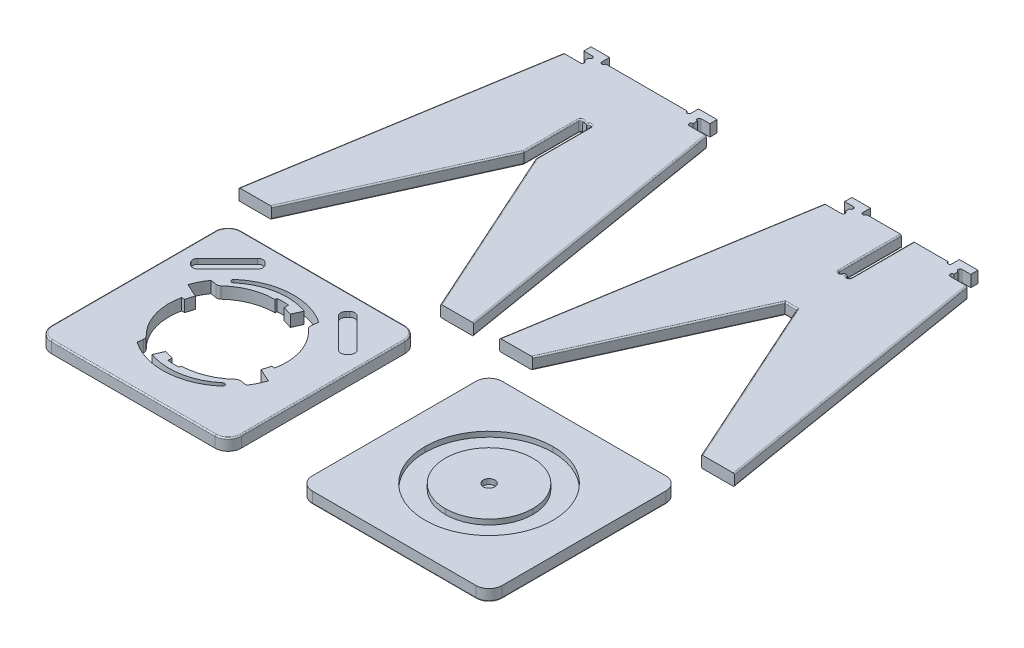
from build123d import *

# Parameters (mm, degrees)
BOSS_EXTRUDE1_DEPTH   = 18
BOSS_EXTRUDE1_2_DEPTH = 18
BOSS_EXTRUDE1_3_DEPTH = 18
BOSS_EXTRUDE1_4_DEPTH = 18
BOSS_EXTRUDE1_5_DEPTH = 18
CUT_EXTRUDE2_DEPTH    = 18
BOSS_EXTRUDE2_START   = -18
BOSS_EXTRUDE2_DEPTH   = 10
FILLET1_R             = 2
FILLET2_R             = 2
FILLET3_R             = 2
FILLET4_R             = 2


with BuildPart() as part:
    # Sketch6 → Boss-Extrude1 (new body)
    with BuildSketch(Plane(origin=(0, 0, 0), x_dir=(1, 0, 0), z_dir=(0, 1, 0))):
        with BuildLine():
            ThreePointArc((-197.70243538, 340.929264228), (-200.767441289, 343.994270137), (-203.832447198, 340.929264228))
            Line((-203.832447198, 340.929264228), (-203.832303055, 256.059392949))
            Line((-203.832303055, 256.059392949), (-325.993914385, -14.127247216))
            Line((-325.993914385, -14.127247216), (-377.067856833, -14.245443905))
            Line((-377.067856833, -14.245443905), (-305.754929566, 418.861386255))
            Line((-305.754929566, 418.861386255), (-279.221754846, 418.861386255))
            ThreePointArc((-279.221754846, 418.861386255), (-276.15673092, 421.926410182), (-279.221754846, 424.991434109))
            Line((-279.221754846, 424.991434109), (-279.221754846, 431.456216427))
            ThreePointArc((-279.221754846, 431.456216427), (-276.156640831, 434.521222336), (-279.22164674, 437.586336351))
            Line((-279.22164674, 437.586336351), (-292.6470609, 437.586156174))
            Line((-292.6470609, 437.586156174), (-292.647096936, 448.824571232))
            Line((-292.647096936, 448.824571232), (-263.847825025, 448.824391055))
            Line((-263.847825025, 448.824391055), (-263.847825025, 437.075351885))
            ThreePointArc((-263.847825025, 437.075351885), (-260.782765063, 434.010291923), (-257.7177051, 437.075351885))
            Line((-257.7177051, 437.075351885), (-131.557153841, 437.075351885))
            ThreePointArc((-131.557153841, 437.075351885), (-128.492039829, 434.010526149), (-125.427105988, 437.075532063))
            Line((-125.427105988, 437.075532063), (-125.427105988, 448.824571232))
            Line((-125.427105988, 448.824571232), (-96.627834076, 448.82475141))
            Line((-96.627834076, 448.82475141), (-96.627762005, 437.586336351))
            Line((-96.627762005, 437.586336351), (-110.053176166, 437.586336351))
            ThreePointArc((-110.053176166, 437.586336351), (-113.118272164, 434.521240353), (-110.053176166, 431.456144356))
            Line((-110.053176166, 431.456144356), (-110.053176166, 424.991362037))
            ThreePointArc((-110.053176166, 424.991362037), (-113.118164057, 421.926374146), (-110.053176166, 418.861386255))
            Line((-110.053176166, 418.861386255), (-83.520181624, 418.861386255))
            Line((-83.520181624, 418.861386255), (-12.206857966, -14.245515977))
            Line((-12.206857966, -14.245515977), (-63.280872485, -14.363784737))
            Line((-63.280872485, -14.363784737), (-185.442555886, 256.059609162))
            Line((-185.442555886, 256.059609162), (-185.442555886, 340.929264228))
            ThreePointArc((-185.442555886, 340.929264228), (-188.507489724, 343.994198066), (-191.572423562, 340.929264228))
            Line((-191.572423562, 340.929264228), (-197.70243538, 340.929264228))
        make_face()
    extrude(amount=BOSS_EXTRUDE1_DEPTH)

    # Fillet3
    fillet3_edges = [part.edges().sort_by_distance(p)[0] for p in [
        (-341.4113932, 18, -202.307971175),
        (-264.91310872, 18, -120.966072866),
        (-188.507489724, 18, -343.994198066),
        (-203.832375126, 18, -298.494328588),
        (-185.442555886, 18, -298.494436695),
        (-124.361714186, 18, -120.847912213),
        (-47.863519795, 18, -202.307935139),
        (-203.832375126, 0, -298.494328588),
        (-264.91310872, 0, -120.966072866),
        (-341.4113932, 0, -202.307971175),
        (-47.863519795, 0, -202.307935139),
        (-200.767441289, 18, -343.994270137),
        (-124.361714186, 0, -120.847912213),
        (-185.442555886, 0, -298.494436695),
        (-188.507489724, 0, -343.994198066),
        (-200.767441289, 0, -343.994270137),
    ]]
    fillet(fillet3_edges, radius=FILLET3_R)


with BuildPart() as body_2:
    # Sketch6 → Boss-Extrude1 2 (new body)
    with BuildSketch(Plane(origin=(0, 0, 0), x_dir=(1, 0, 0), z_dir=(0, 1, 0))):
        with BuildLine():
            Line((126.274869301, 431.456216427), (126.274869301, 424.991434109))
            ThreePointArc((126.274869301, 424.991434109), (129.339695037, 421.926410182), (126.274869301, 418.861386255))
            Line((126.274869301, 418.861386255), (99.741514403, 418.861386255))
            Line((99.741514403, 418.861386255), (28.428587137, -14.245515977))
            Line((28.428587137, -14.245515977), (79.502601656, -14.008762243))
            Line((79.502601656, -14.008762243), (201.663996772, 256.216904451))
            Line((201.663996772, 256.216904451), (220.164661444, 256.216904451))
            Line((220.164661444, 256.216904451), (342.155536215, -14.36367663))
            Line((342.155536215, -14.36367663), (393.289441861, -14.245515977))
            Line((393.289441861, -14.245515977), (321.976478559, 418.861386255))
            Line((321.976478559, 418.861386255), (295.443484017, 418.861386255))
            ThreePointArc((295.443484017, 418.861386255), (292.378496126, 421.926392164), (295.443520053, 424.991362037))
            Line((295.443520053, 424.991362037), (295.443520053, 431.456144356))
            ThreePointArc((295.443520053, 431.456144356), (292.378424055, 434.521240353), (295.443520053, 437.586336351))
            Line((295.443520053, 437.586336351), (308.868934213, 437.586336351))
            Line((308.868934213, 437.586336351), (308.868790071, 448.82475141))
            Line((308.868790071, 448.82475141), (280.06951816, 448.824571232))
            Line((280.06951816, 448.824571232), (280.069446089, 437.075532063))
            ThreePointArc((280.069446089, 437.075532063), (277.004530266, 434.01052615), (273.939434271, 437.075351885))
            Line((273.939434271, 437.075351885), (220.054356546, 437.075351885))
            Line((220.054356546, 437.075351885), (220.054104297, 340.730600098))
            ThreePointArc((220.054104297, 340.730600098), (217.043708877, 337.558462502), (213.924020408, 340.623178046))
            Line((213.924020408, 340.623178046), (207.79400859, 340.623178046))
            ThreePointArc((207.79400859, 340.623178046), (204.729002681, 337.558172137), (201.663996772, 340.623178046))
            Line((201.663996772, 340.623178046), (201.66417695, 437.075351885))
            Line((201.66417695, 437.075351885), (147.778738869, 437.075351885))
            ThreePointArc((147.778738869, 437.075351885), (144.713696925, 434.01030994), (141.64865498, 437.075351885))
            Line((141.64865498, 437.075351885), (141.64865498, 448.824391055))
            Line((141.64865498, 448.824391055), (112.849743425, 448.824571232))
            Line((112.849743425, 448.824571232), (112.849599283, 437.586156174))
            Line((112.849599283, 437.586156174), (126.275013443, 437.586336351))
            ThreePointArc((126.275013443, 437.586336351), (129.34011272, 434.521204315), (126.274869301, 431.456216427))
        make_face()
    extrude(amount=BOSS_EXTRUDE1_2_DEPTH)

    # Fillet4
    fillet4_edges = [body_2.edges().sort_by_distance(p)[0] for p in [
        (204.729002681, 0, -337.558172137),
        (204.729002681, 18, -337.558172137),
        (201.664086861, 0, -388.849264965),
        (220.054230422, 0, -388.902975991),
        (220.054230422, 18, -388.902975991),
        (201.664086861, 18, -388.849264965),
        (357.63296021, 0, -202.307935139),
        (357.63296021, 18, -202.307935139),
        (64.08505077, 0, -202.307935139),
        (64.08505077, 18, -202.307935139),
        (140.583299214, 0, -121.104071104),
        (140.583299214, 18, -121.104071104),
        (210.914329108, 0, -256.216904451),
        (210.914329108, 18, -256.216904451),
        (281.160098829, 0, -120.92661391),
        (281.160098829, 18, -120.92661391),
    ]]
    fillet(fillet4_edges, radius=FILLET4_R)


with BuildPart() as body_3:
    # Sketch6 → Boss-Extrude1 3 (new body)
    with BuildSketch(Plane(origin=(0, 0, 0), x_dir=(1, 0, 0), z_dir=(0, 1, 0))):
        with BuildLine():
            Line((88.692898723, -70.548220489), (342.99307507, -70.548220489))
            ThreePointArc((342.99307507, -70.548220489), (357.439018451, -76.531926159), (363.42272412, -90.977869539))
            Line((363.42272412, -90.977869539), (363.42272412, -345.277685531))
            ThreePointArc((363.42272412, -345.277685531), (357.439018451, -359.723628912), (342.99307507, -365.707334581))
            Line((342.99307507, -365.707334581), (88.692898723, -365.707334581))
            ThreePointArc((88.692898723, -365.707334581), (74.246955342, -359.723628912), (68.263249672, -345.277685531))
            Line((68.263249672, -345.277685531), (68.263249672, -90.977869539))
            ThreePointArc((68.263249672, -90.977869539), (74.246955342, -76.531926159), (88.692898723, -70.548220489))
        make_face()
        with BuildLine():
            add(Edge.make_bspline(
                [(215.84320311, -317.479662097), (270.71349348, -317.479662097), (315.195087671, -272.998428261), (315.195087671, -218.127777535)],
                knots=[3, 3, 3, 3, 4, 4, 4, 4], degree=3))
            add(Edge.make_bspline(
                [(315.195087671, -218.127777535), (315.195087671, -163.257126809), (270.71349348, -118.775892974), (215.84320311, -118.775892974)],
                knots=[0, 0, 0, 0, 1, 1, 1, 1], degree=3))
            add(Edge.make_bspline(
                [(215.84320311, -118.775892974), (160.972552384, -118.775892974), (116.490958193, -163.257126809), (116.490958193, -218.127777535)],
                knots=[1, 1, 1, 1, 2, 2, 2, 2], degree=3))
            add(Edge.make_bspline(
                [(116.490958193, -218.127777535), (116.490958193, -272.998428261), (160.972552384, -317.479662097), (215.84320311, -317.479662097)],
                knots=[2, 2, 2, 2, 3, 3, 3, 3], degree=3))
        make_face(mode=Mode.SUBTRACT)
    extrude(amount=BOSS_EXTRUDE1_3_DEPTH)



with BuildPart() as body_4:
    # Sketch6 → Boss-Extrude1 4 (new body)
    with BuildSketch(Plane(origin=(0, 0, 0), x_dir=(1, 0, 0), z_dir=(0, 1, 0))):
        with BuildLine():
            Line((-316.803509211, -70.548076347), (-62.503332864, -70.548076347))
            ThreePointArc((-62.503332864, -70.548076347), (-48.057389483, -76.531782016), (-42.073683814, -90.977725397))
            Line((-42.073683814, -90.977725397), (-42.073683814, -345.277541389))
            ThreePointArc((-42.073683814, -345.277541389), (-48.057389483, -359.723484769), (-62.503332864, -365.707190439))
            Line((-62.503332864, -365.707190439), (-316.803509211, -365.707190439))
            ThreePointArc((-316.803509211, -365.707190439), (-331.249452592, -359.723484769), (-337.233158262, -345.277541389))
            Line((-337.233158262, -345.277541389), (-337.233158262, -90.977725397))
            ThreePointArc((-337.233158262, -90.977725397), (-331.249452592, -76.531782016), (-316.803509211, -70.548076347))
        make_face()
        with BuildLine():
            ThreePointArc((-255.417049792, -95.030034015), (-261.195534567, -92.63629615), (-266.974019342, -95.030034015))
            Line((-266.974019342, -95.030034015), (-313.200816474, -141.257191503))
            ThreePointArc((-313.200816474, -141.257191503), (-315.594255413, -147.0354961), (-313.200816474, -152.813800697))
            Line((-313.200816474, -152.813800697), (-310.311844354, -155.702772818))
            ThreePointArc((-310.311844354, -155.702772818), (-304.533359579, -158.096299582), (-298.754874804, -155.702772818))
            Line((-298.754874804, -155.702772818), (-252.528077671, -109.475975685))
            ThreePointArc((-252.528077671, -109.475975685), (-250.13462554, -103.697671088), (-252.528077671, -97.919366491))
            Line((-252.528077671, -97.919366491), (-255.417049792, -95.030034015))
        make_face(mode=Mode.SUBTRACT)
        with BuildLine():
            Line((-66.106025601, -152.813800697), (-68.994997722, -155.702772818))
            ThreePointArc((-68.994997722, -155.702772818), (-74.773482497, -158.096299582), (-80.551967272, -155.702772818))
            Line((-80.551967272, -155.702772818), (-126.778764404, -109.475975685))
            ThreePointArc((-126.778764404, -109.475975685), (-129.172216536, -103.697671088), (-126.778764404, -97.919366491))
            Line((-126.778764404, -97.919366491), (-123.889792284, -95.030034015))
            ThreePointArc((-123.889792284, -95.030034015), (-118.111307509, -92.63629615), (-112.332822734, -95.030034015))
            Line((-112.332822734, -95.030034015), (-66.106025601, -141.257191503))
            ThreePointArc((-66.106025601, -141.257191503), (-63.712586663, -147.0354961), (-66.106025601, -152.813800697))
        make_face(mode=Mode.SUBTRACT)
    extrude(amount=BOSS_EXTRUDE1_4_DEPTH)

    # Sketch7 → Cut-Extrude2 (cut)
    with BuildSketch(Plane(origin=(0, 0, 0), x_dir=(1, 0, 0), z_dir=(0, 1, 0))):
        with BuildLine():
            Line((-133.496264216, -133.316500102), (-134.789797249, -144.296143691))
            ThreePointArc((-134.789797249, -144.296143691), (-134.416044892, -147.630155792), (-132.524132485, -150.400714392))
            ThreePointArc((-132.524132485, -150.400714392), (-108.804185347, -186.400825268), (-106.131676689, -229.429903492))
            Line((-106.131676689, -229.429903492), (-110.819688901, -229.196428996))
            Line((-110.819688901, -229.196428996), (-114.524398354, -242.142497926))
            Line((-114.524398354, -242.142497926), (-93.581206311, -251.655781859))
            ThreePointArc((-93.581206311, -251.655781859), (-98.530835117, -263.403623432), (-104.920917374, -274.43437389))
            Line((-104.920917374, -274.43437389), (-115.444746963, -273.04844564))
            ThreePointArc((-115.444746963, -273.04844564), (-118.539629536, -273.391255145), (-121.257717784, -274.910403848))
            ThreePointArc((-121.257717784, -274.910403848), (-149.060818706, -292.68177622), (-181.368049353, -299.395712824))
            Line((-181.368049353, -299.395712824), (-181.215258512, -302.31315305))
            ThreePointArc((-181.215258512, -302.31315305), (-190.335032474, -302.636547449), (-199.440575348, -302.033264732))
            Line((-199.440575348, -302.033264732), (-199.120471327, -295.608626045))
            Line((-199.120471327, -295.608626045), (-212.906241247, -291.663198946))
            Line((-212.906241247, -291.663198946), (-219.602732318, -306.405713406))
            add(Edge.make_bspline(
                [(-219.602732318, -306.405713406), (-187.834849664, -317.826468479), (-152.387013997, -311.43231589), (-126.611126905, -289.632954599)],
                knots=[0, 0, 0, 0, 1, 1, 1, 1], degree=3))
            ThreePointArc((-126.611126905, -289.632954599), (-122.106932166, -290.009418261), (-122.483395827, -294.513613))
            add(Edge.make_bspline(
                [(-247.841795166, -301.557847379), (-209.419222709, -328.356784471), (-157.662045741, -325.44835314), (-122.483395827, -294.513613)],
                knots=[0, 0, 0, 0, 1, 1, 1, 1], degree=3))
            Line((-247.841795166, -301.557847379), (-246.570964546, -292.623547044))
            ThreePointArc((-246.570964546, -292.623547044), (-246.8842088, -289.288349752), (-248.689387947, -286.466472508))
            ThreePointArc((-248.689387947, -286.466472508), (-271.281564756, -249.828071678), (-273.174480711, -206.82579572))
            Line((-273.174480711, -206.82579572), (-268.486684712, -207.058945897))
            Line((-268.486684712, -207.058945897), (-264.781614903, -194.112876966))
            Line((-264.781614903, -194.112876966), (-285.724879017, -184.599412855))
            ThreePointArc((-285.724879017, -184.599412855), (-280.502702563, -172.344313248), (-273.741608604, -160.866238419))
            Line((-273.741608604, -160.866238419), (-264.232901189, -162.257572005))
            ThreePointArc((-264.232901189, -162.257572005), (-261.109425771, -162.037957154), (-258.393876647, -160.479072191))
            ThreePointArc((-258.393876647, -160.479072191), (-230.401343633, -142.947729401), (-197.938072011, -136.859553961))
            Line((-197.938072011, -136.859553961), (-198.090898888, -133.942185807))
            ThreePointArc((-198.090898888, -133.942185807), (-188.969243412, -133.49735286), (-179.865546016, -134.222038089))
            Line((-179.865546016, -134.222038089), (-180.185505894, -140.647325416))
            Line((-180.185505894, -140.647325416), (-166.400168401, -144.592536303))
            Line((-166.400168401, -144.592536303), (-159.703316974, -129.849661486))
            add(Edge.make_bspline(
                [(-159.703316974, -129.849661486), (-191.471199629, -118.428906413), (-226.919035295, -124.823059003), (-252.694562032, -146.622780649)],
                knots=[0, 0, 0, 0, 1, 1, 1, 1], degree=3))
            ThreePointArc((-252.694562032, -146.622780649), (-257.198991003, -146.246407077), (-256.82261743, -141.741978106))
            add(Edge.make_bspline(
                [(-133.496264216, -133.316500102), (-171.792351803, -107.958625691), (-222.331165948, -111.411194219), (-256.82261743, -141.741978106)],
                knots=[0, 0, 0, 0, 1, 1, 1, 1], degree=3))
        make_face()
    extrude(amount=CUT_EXTRUDE2_DEPTH, mode=Mode.SUBTRACT)


with BuildPart() as body_5:
    # Sketch6 → Boss-Extrude1 5 (new body)
    with BuildSketch(Plane(origin=(0, 0, 0), x_dir=(1, 0, 0), z_dir=(0, 1, 0))):
        with BuildLine():
            add(Edge.make_bspline(
                [(283.78377704, -218.127777535), (283.78377704, -180.605013408), (253.365787059, -150.187023427), (215.843022932, -150.187023427)],
                knots=[0, 0, 0, 0, 1, 1, 1, 1], degree=3))
            add(Edge.make_bspline(
                [(215.843022932, -150.187023427), (178.32061916, -150.187023427), (147.902268824, -180.605013408), (147.902268824, -218.127777535)],
                knots=[1, 1, 1, 1, 2, 2, 2, 2], degree=3))
            add(Edge.make_bspline(
                [(147.902268824, -218.127777535), (147.902268824, -255.650181307), (178.32061916, -286.068531643), (215.843022932, -286.068531643)],
                knots=[2, 2, 2, 2, 3, 3, 3, 3], degree=3))
            add(Edge.make_bspline(
                [(215.843022932, -286.068531643), (253.365787059, -286.068531643), (283.78377704, -255.650181307), (283.78377704, -218.127777535)],
                knots=[3, 3, 3, 3, 4, 4, 4, 4], degree=3))
        make_face()
        with BuildLine():
            add(Edge.make_bspline(
                [(215.843022932, -209.034956702), (220.864940791, -209.034956702), (224.935879801, -213.105535356), (224.935879801, -218.127453215)],
                knots=[3, 3, 3, 3, 4, 4, 4, 4], degree=3))
            add(Edge.make_bspline(
                [(224.935879801, -218.127453215), (224.935879801, -223.149010718), (220.864940791, -227.220310084), (215.843022932, -227.220310084)],
                knots=[0, 0, 0, 0, 1, 1, 1, 1], degree=3))
            add(Edge.make_bspline(
                [(215.843022932, -227.220310084), (210.821105073, -227.220310084), (206.750166063, -223.149010718), (206.750166063, -218.127453215)],
                knots=[1, 1, 1, 1, 2, 2, 2, 2], degree=3))
            add(Edge.make_bspline(
                [(206.750166063, -218.127453215), (206.750166063, -213.105535356), (210.821105073, -209.034956702), (215.843022932, -209.034956702)],
                knots=[2, 2, 2, 2, 3, 3, 3, 3], degree=3))
        make_face(mode=Mode.SUBTRACT)
    extrude(amount=BOSS_EXTRUDE1_5_DEPTH)


with BuildPart() as body_3_1:
    add(body_3.part)

    add(body_4.part)  # Boss-Extrude2 merges body 4

    add(body_5.part)  # Boss-Extrude2 merges body 5
    # Sketch8 → Boss-Extrude2 (add)
    with BuildSketch(Plane(origin=(0, 18, 0), x_dir=(1, 0, 0), z_dir=(0, 1, 0)).offset(BOSS_EXTRUDE2_START)):
        with BuildLine():
            add(Edge.make_bspline(
                [(315.195087671, -218.127777535), (315.195087671, -272.998428261), (270.71349348, -317.479662097), (215.84320311, -317.479662097)],
                knots=[3, 3, 3, 3, 4, 4, 4, 4], degree=3))
            add(Edge.make_bspline(
                [(215.84320311, -317.479662097), (160.972552384, -317.479662097), (116.490958193, -272.998428261), (116.490958193, -218.127777535)],
                knots=[2, 2, 2, 2, 3, 3, 3, 3], degree=3))
            add(Edge.make_bspline(
                [(116.490958193, -218.127777535), (116.490958193, -163.257126809), (160.972552384, -118.775892974), (215.84320311, -118.775892974)],
                knots=[1, 1, 1, 1, 2, 2, 2, 2], degree=3))
            add(Edge.make_bspline(
                [(215.84320311, -118.775892974), (270.71349348, -118.775892974), (315.195087671, -163.257126809), (315.195087671, -218.127777535)],
                knots=[0, 0, 0, 0, 1, 1, 1, 1], degree=3))
        make_face()
        with BuildLine():
            add(Edge.make_bspline(
                [(147.902268824, -218.127777535), (147.902268824, -255.650181307), (178.32061916, -286.068531643), (215.843022932, -286.068531643)],
                knots=[2, 2, 2, 2, 3, 3, 3, 3], degree=3))
            add(Edge.make_bspline(
                [(215.843022932, -286.068531643), (253.365787059, -286.068531643), (283.78377704, -255.650181307), (283.78377704, -218.127777535)],
                knots=[3, 3, 3, 3, 4, 4, 4, 4], degree=3))
            add(Edge.make_bspline(
                [(283.78377704, -218.127777535), (283.78377704, -180.605013408), (253.365787059, -150.187023427), (215.843022932, -150.187023427)],
                knots=[0, 0, 0, 0, 1, 1, 1, 1], degree=3))
            add(Edge.make_bspline(
                [(215.843022932, -150.187023427), (178.32061916, -150.187023427), (147.902268824, -180.605013408), (147.902268824, -218.127777535)],
                knots=[1, 1, 1, 1, 2, 2, 2, 2], degree=3))
        make_face(mode=Mode.SUBTRACT)
        with BuildLine():
            add(Edge.make_bspline(
                [(224.935879801, -218.127453215), (224.935879801, -223.149010718), (220.864940791, -227.220310084), (215.843022932, -227.220310084)],
                knots=[0, 0, 0, 0, 1, 1, 1, 1], degree=3))
            add(Edge.make_bspline(
                [(215.843022932, -227.220310084), (210.821105073, -227.220310084), (206.750166063, -223.149010718), (206.750166063, -218.127453215)],
                knots=[1, 1, 1, 1, 2, 2, 2, 2], degree=3))
            add(Edge.make_bspline(
                [(206.750166063, -218.127453215), (206.750166063, -213.105535356), (210.821105073, -209.034956702), (215.843022932, -209.034956702)],
                knots=[2, 2, 2, 2, 3, 3, 3, 3], degree=3))
            add(Edge.make_bspline(
                [(215.843022932, -209.034956702), (220.864940791, -209.034956702), (224.935879801, -213.105535356), (224.935879801, -218.127453215)],
                knots=[3, 3, 3, 3, 4, 4, 4, 4], degree=3))
        make_face()
        with BuildLine():
            Line((-252.528077671, -97.919366491), (-255.417049792, -95.030034015))
            ThreePointArc((-255.417049792, -95.030034015), (-261.195534567, -92.63629615), (-266.974019342, -95.030034015))
            Line((-266.974019342, -95.030034015), (-313.200816474, -141.257191503))
            ThreePointArc((-313.200816474, -141.257191503), (-315.594255413, -147.0354961), (-313.200816474, -152.813800697))
            Line((-313.200816474, -152.813800697), (-310.311844354, -155.702772818))
            ThreePointArc((-310.311844354, -155.702772818), (-304.533359579, -158.096299582), (-298.754874804, -155.702772818))
            Line((-298.754874804, -155.702772818), (-252.528077671, -109.475975685))
            ThreePointArc((-252.528077671, -109.475975685), (-250.13462554, -103.697671088), (-252.528077671, -97.919366491))
        make_face()
        with BuildLine():
            Line((-126.778764404, -97.919366491), (-123.889792284, -95.030034015))
            ThreePointArc((-123.889792284, -95.030034015), (-118.111307509, -92.63629615), (-112.332822734, -95.030034015))
            Line((-112.332822734, -95.030034015), (-66.106025601, -141.257191503))
            ThreePointArc((-66.106025601, -141.257191503), (-63.712586663, -147.0354961), (-66.106025601, -152.813800697))
            Line((-66.106025601, -152.813800697), (-68.994997722, -155.702772818))
            ThreePointArc((-68.994997722, -155.702772818), (-74.773482497, -158.096299582), (-80.551967272, -155.702772818))
            Line((-80.551967272, -155.702772818), (-126.778764404, -109.475975685))
            ThreePointArc((-126.778764404, -109.475975685), (-129.172216536, -103.697671088), (-126.778764404, -97.919366491))
        make_face()
    extrude(amount=BOSS_EXTRUDE2_DEPTH)

    # Fillet1
    fillet1_edges = [body_3_1.edges().sort_by_distance(p)[0] for p in [
        (357.439018451, 0, 76.531926159),
        (363.42272412, 0, 218.127777535),
        (357.439018451, 0, 359.723628912),
        (215.842986896, 0, 365.707334581),
        (74.246955342, 0, 359.723628912),
        (68.263249672, 0, 218.127777535),
        (74.246955342, 0, 76.531926159),
        (215.842986896, 0, 70.548220489),
    ]]
    fillet(fillet1_edges, radius=FILLET1_R)

    # Fillet2
    fillet2_edges = [body_3_1.edges().sort_by_distance(p)[0] for p in [
        (-189.653421038, 18, 70.548076347),
        (-331.249452592, 18, 76.531782016),
        (-337.233158262, 18, 218.127633393),
        (-331.249452592, 18, 359.723484769),
        (-189.653421038, 18, 365.707190439),
        (-48.057389483, 18, 359.723484769),
        (-42.073683814, 18, 218.127633393),
        (-48.057389483, 18, 76.531782016),
    ]]
    fillet(fillet2_edges, radius=FILLET2_R)


solid = Compound([part.part, body_2.part, body_3_1.part])
